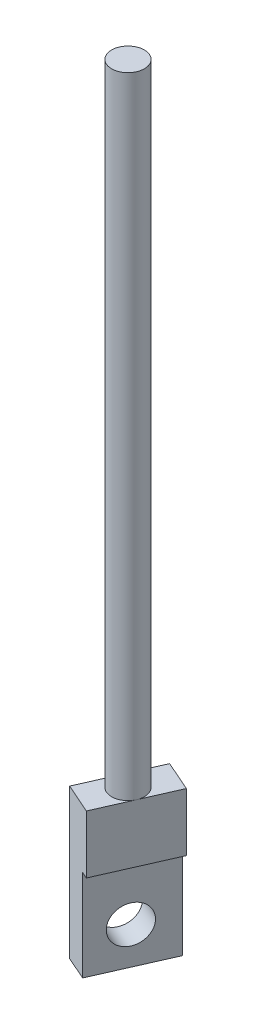
from build123d import *

# Parameters (mm, degrees)
SKETCH2_R           = 3.5
BOSS_EXTRUDE1_DEPTH = 135
BOSS_EXTRUDE2_DEPTH = 7
SKETCH4_R           = 4
CUT_EXTRUDE1_DEPTH  = 7
SKETCH5_W           = 1.564160686
SKETCH5_H           = 19.573383476
CUT_EXTRUDE2_DEPTH  = 19.821098843


with BuildPart() as part:
    # Sketch2 → Boss-Extrude1 (new body)
    with BuildSketch(Plane(origin=(0, 0, 0), x_dir=(1, 0, 0), z_dir=(0, 1, 0))):
        with Locations((-10.295474734, 5.826559877)):
            Circle(SKETCH2_R)
    extrude(amount=BOSS_EXTRUDE1_DEPTH)

    # Sketch3 → Boss-Extrude2 (add)
    with BuildSketch(Plane(origin=(-7.567781688, 0, -3.338011531), x_dir=(-0.403567776, 0, 0.914949753), z_dir=(-0.914949753, 0, -0.403567776))):
        Polygon((-9.296087677, 0.018668346), (-9.296087677, -32), (6.940301507, -32), (6.940301507, 0), align=None)
    extrude(amount=BOSS_EXTRUDE2_DEPTH)

    # Sketch4 → Cut-Extrude1 (cut)
    with BuildSketch(Plane(origin=(-7.567781688, 0, -3.338011531), x_dir=(0.403567776, 0, -0.914949753), z_dir=(0.914949753, 0, 0.403567776))):
        with Locations((0.894610349, -24.070410288)):
            Circle(SKETCH4_R)
    extrude(amount=-CUT_EXTRUDE1_DEPTH, mode=Mode.SUBTRACT)

    # Sketch5 → Cut-Extrude2 (cut, through all)
    with BuildSketch(Plane(origin=(-2.800882044, 0, 6.350027148), x_dir=(0.914949753, 0, 0.403567776), z_dir=(-0.403567776, 0, 0.914949753))):
        with Locations((-9.053334217, -22.213308262)):
            Rectangle(SKETCH5_W, SKETCH5_H)
    extrude(amount=-CUT_EXTRUDE2_DEPTH, mode=Mode.SUBTRACT)


solid = part.part
